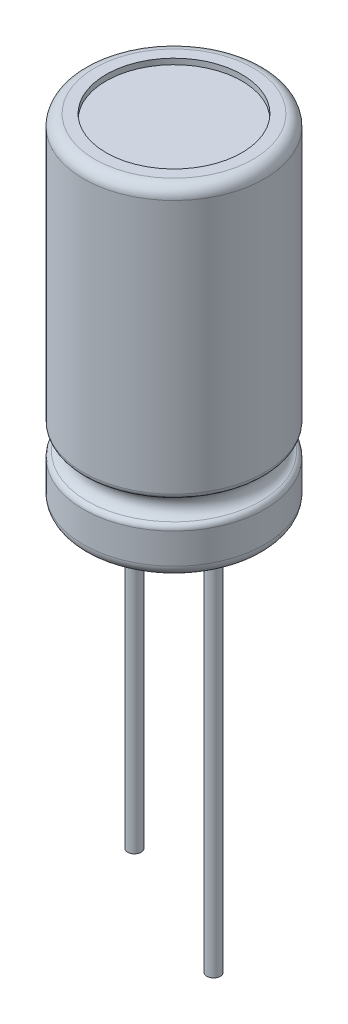
from build123d import *

# Parameters (mm, degrees)
SKETCH1_R           = 4
BASE_EXTRUDE_DEPTH  = 15
FILLET1_R           = 0.5
FILLET2_R           = 0.25
SKETCH4_R           = 3
CUT_EXTRUDE1_DEPTH  = 0.25
SKETCH3_R           = 0.3
BOSS_EXTRUDE1_DEPTH = 17.25
SKETCH5_R           = 0.3
CUT_EXTRUDE2_DEPTH  = 3
SKETCH6_R           = 3
CUT_EXTRUDE3_DEPTH  = 0.25


with BuildPart() as part:
    # Sketch1 → Base-Extrude (new body)
    with BuildSketch(Plane(origin=(0, 0, 0), x_dir=(1, 0, 0), z_dir=(0, 1, 0))):
        with Locations(Location((0, 0, 0), (0, 0, 270))):  # turned: the seam where the file's is
            Circle(SKETCH1_R)
    extrude(amount=BASE_EXTRUDE_DEPTH)

    # Sketch2 → Cut-Revolve1 (revolve, cut)
    with BuildSketch(Plane(origin=(0, 0, 0), x_dir=(0, 0, -1), z_dir=(1, 0, 0)), mode=Mode.PRIVATE) as cut_revolve1_sk:
        with BuildLine():
            Line((-4, 3.053185949), (-4, 2.053185949))
            ThreePointArc((-4, 2.053185949), (-3.5, 2.553185949), (-4, 3.053185949))
        make_face()
    revolve(cut_revolve1_sk.sketch.rotate(Axis((0, 0, 0), (0, 1, 0)), 180), axis=Axis((0, 0, 0), (0, 1, 0)), mode=Mode.SUBTRACT)  # turned: the seam where the file's is

    # Fillet1
    fillet1_edges = [part.edges().sort_by_distance(p)[0] for p in [
        (0, 0, -4),
        (0, 15, -4),
    ]]
    fillet(fillet1_edges, radius=FILLET1_R)

    # Fillet2
    fillet2_edges = [part.edges().sort_by_distance(p)[0] for p in [
        (-4, 2.053185949, 0),
        (-4, 3.053185949, 0),
    ]]
    fillet(fillet2_edges, radius=FILLET2_R)

    # Sketch4 → Cut-Extrude1 (cut)
    with BuildSketch(Plane.XZ):
        with Locations(Location((0, 0, 0), (0, 0, 270))):  # turned: the seam where the file's is
            Circle(SKETCH4_R)
    extrude(amount=-CUT_EXTRUDE1_DEPTH, mode=Mode.SUBTRACT)

    # Sketch3 → Boss-Extrude1 (add)
    with BuildSketch(Plane.XZ.offset(-0.25)):
        with Locations(Location((-1.75, 0, 0), (0, 0, 270))):  # turned: the seam where the file's is
            Circle(SKETCH3_R)
        with Locations(Location((1.75, 0, 0), (0, 0, 270))):  # turned: the seam where the file's is
            Circle(SKETCH3_R)
    extrude(amount=BOSS_EXTRUDE1_DEPTH)

    # Sketch5 → Cut-Extrude2 (cut)
    with BuildSketch(Plane.XZ.offset(17)):
        with Locations(Location((-1.75, 0, 0), (0, 0, 270))):  # turned: the seam where the file's is
            Circle(SKETCH5_R)
    extrude(amount=-CUT_EXTRUDE2_DEPTH, mode=Mode.SUBTRACT)

    # Sketch6 → Cut-Extrude3 (cut)
    with BuildSketch(Plane(origin=(0, 15, 0), x_dir=(-1, 0, 0), z_dir=(0, 1, 0))):
        with Locations(Location((0, 0, 0), (0, 0, 270))):  # turned: the seam where the file's is
            Circle(SKETCH6_R)
    extrude(amount=-CUT_EXTRUDE3_DEPTH, mode=Mode.SUBTRACT)


solid = part.part
